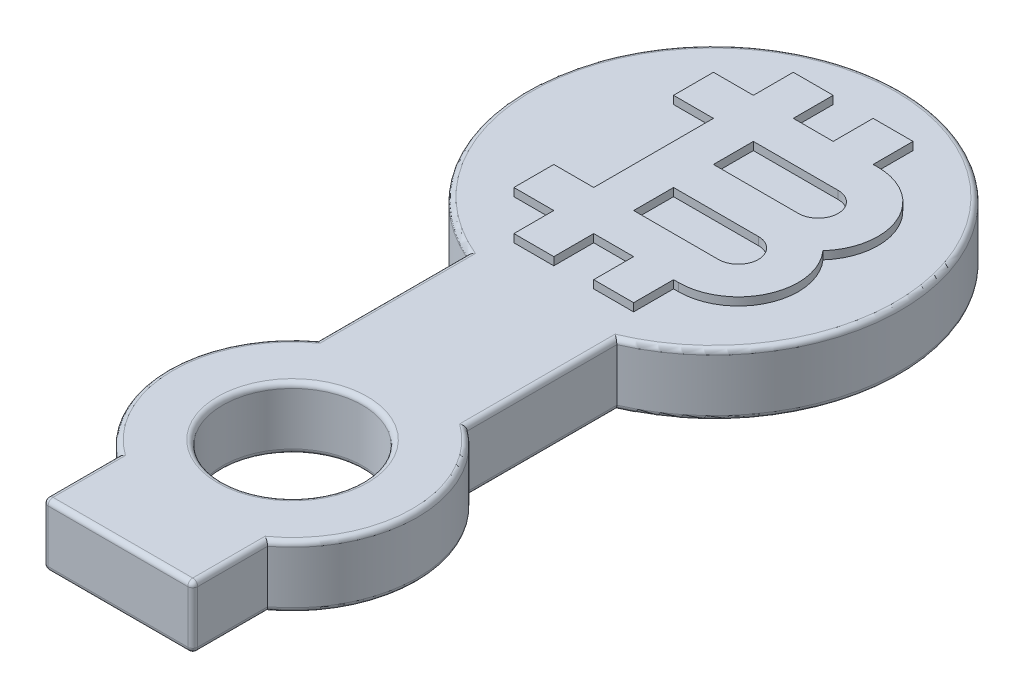
from build123d import *

# Parameters (mm, degrees)
SKETCH_4_R      = 2.8
EXTRUDE_2_DEPTH = 2.5
FILLET_1_R      = 0.2
EXTRUDE_3_DEPTH = 0.32


with BuildPart() as part:
    # 草图4 → 凸台-拉伸2 (new body)
    with BuildSketch(Plane(origin=(0, 0, 0), x_dir=(1, 0, 0), z_dir=(0, 1, 0))):
        with BuildLine():
            Line((-3, 10), (-3, 4))
            ThreePointArc((-3, 4), (-5, 0), (-3, -4))
            Line((-3, -4), (-3, -7))
            Line((-3, -7), (3, -7))
            Line((3, -7), (3, -4))
            ThreePointArc((3, -4), (5, 0), (3, 4))
            Line((3, 4), (3, 10))
            ThreePointArc((3, 10), (0, 24.373863542), (-3, 10))
        make_face()
        Circle(SKETCH_4_R, mode=Mode.SUBTRACT)
    extrude(amount=EXTRUDE_2_DEPTH)

    # 圆角1
    fillet_1_edges = [part.edges().sort_by_distance(p)[0] for p in [
        (-2.8, 0, 0),
        (-5, 2.5, 0),
        (0, 0, -24.373863542),
        (3, 0, -7),
        (5, 0, 0),
        (3, 0, 5.5),
        (0, 0, 7),
        (-3, 0, 5.5),
        (-5, 0, 0),
        (-3, 0, -7),
        (-3, 2.5, 5.5),
        (3, 1.25, 7),
        (-3, 1.25, 7),
        (0, 2.5, 7),
        (3, 2.5, 5.5),
        (5, 2.5, 0),
        (3, 2.5, -7),
        (0, 2.5, -24.373863542),
        (-2.8, 2.5, 0),
        (-3, 2.5, -7),
    ]]
    fillet(fillet_1_edges, radius=FILLET_1_R)

    # 草图1 → 凸台-拉伸3 (add)
    with BuildSketch(Plane(origin=(0, 2.5, 0), x_dir=(1, 0, 0), z_dir=(0, 1, 0))):
        with BuildLine():
            Line((-0.8, 22.473863542), (-2.4, 22.473863542))
            Line((-2.4, 22.473863542), (-2.4, 20.873863542))
            Line((-2.4, 20.873863542), (-4, 20.873863542))
            Line((-4, 20.873863542), (-4, 19.273863542))
            Line((-4, 19.273863542), (-2.4, 19.273863542))
            Line((-2.4, 19.273863542), (-2.4, 14.473863542))
            Line((-2.4, 14.473863542), (-4, 14.473863542))
            Line((-4, 14.473863542), (-4, 12.873863542))
            Line((-4, 12.873863542), (-2.4, 12.873863542))
            Line((-2.4, 12.873863542), (-2.4, 11.273863542))
            Line((-2.4, 11.273863542), (-0.8, 11.273863542))
            Line((-0.8, 11.273863542), (-0.8, 12.873863542))
            Line((-0.8, 12.873863542), (0.8, 12.873863542))
            Line((0.8, 12.873863542), (0.8, 11.273863542))
            Line((0.8, 11.273863542), (2.4, 11.273863542))
            Line((2.4, 11.273863542), (2.4, 12.873863542))
            Line((2.4, 12.873863542), (2.6, 12.873863542))
            ThreePointArc((2.6, 12.873863542), (4.79089023, 14.294067645), (4.388854382, 16.873863542))
            ThreePointArc((4.388854382, 16.873863542), (4.79089023, 19.45365944), (2.6, 20.873863542))
            Line((2.6, 20.873863542), (2.4, 20.873863542))
            Line((2.4, 20.873863542), (2.4, 22.473863542))
            Line((2.4, 22.473863542), (0.8, 22.473863542))
            Line((0.8, 22.473863542), (0.8, 20.873863542))
            Line((0.8, 20.873863542), (-0.8, 20.873863542))
            Line((-0.8, 20.873863542), (-0.8, 22.473863542))
        make_face()
        with BuildLine():
            Line((-0.8, 17.673863542), (2.6, 17.673863542))
            ThreePointArc((2.6, 17.673863542), (3.4, 18.473863542), (2.6, 19.273863542))
            Line((2.6, 19.273863542), (-0.8, 19.273863542))
            Line((-0.8, 19.273863542), (-0.8, 17.673863542))
        make_face(mode=Mode.SUBTRACT)
        with BuildLine():
            Line((2.6, 16.073863542), (-0.8, 16.073863542))
            Line((-0.8, 16.073863542), (-0.8, 14.473863542))
            Line((-0.8, 14.473863542), (2.6, 14.473863542))
            ThreePointArc((2.6, 14.473863542), (3.4, 15.273863542), (2.6, 16.073863542))
        make_face(mode=Mode.SUBTRACT)
    extrude(amount=EXTRUDE_3_DEPTH)


solid = part.part
